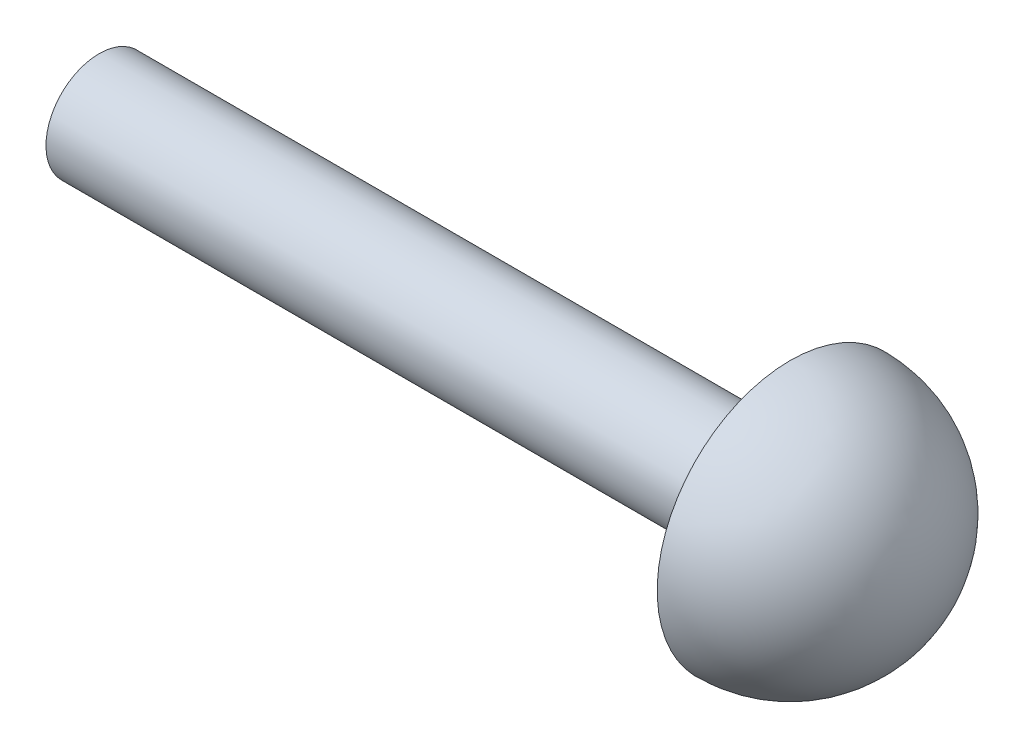
from build123d import *


with BuildPart() as part:
    # 草圖1 → 旋轉1 (revolve)
    with BuildSketch(Plane.XY):
        with BuildLine():
            Line((0, 0), (-26, 0))
            Line((-26, 0), (-26, 2))
            Line((-26, 2), (0, 2))
            Line((0, 2), (0, 5))
            ThreePointArc((0, 5), (3.535533906, 3.535533906), (5, 0))
            Line((5, 0), (0, 0))
        make_face()
    revolve(axis=Axis((0, 0, 0), (-1, 0, 0)))


solid = part.part
